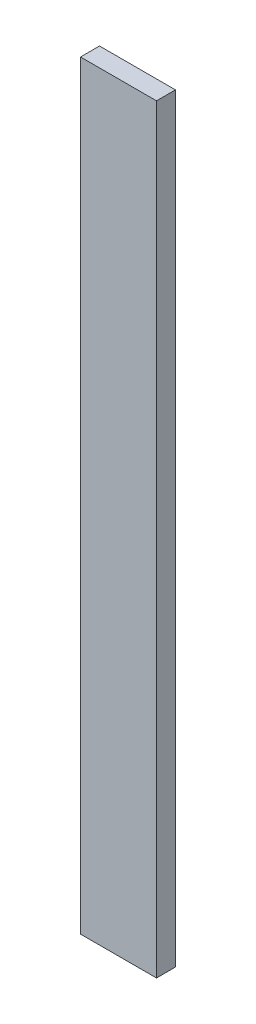
from build123d import *

# Parameters (mm, degrees)
SKETCH1_W   = 12.7
SKETCH1_H   = 127
STRIP_DEPTH = 3.175


with BuildPart() as part:
    # Sketch1 → Strip (new body)
    with BuildSketch(Plane.XY):
        with Locations((6.35, -63.5)):
            Rectangle(SKETCH1_W, SKETCH1_H)
    extrude(amount=STRIP_DEPTH)


solid = part.part
